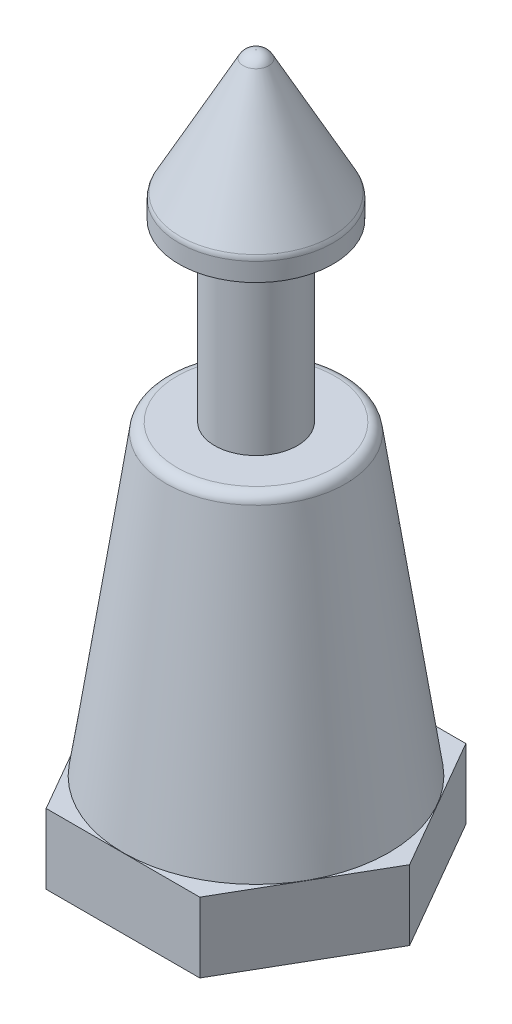
from build123d import *

# Parameters (mm, degrees)
BOSS_EXTRUDE1_DEPTH = 2.54
FILLET1_R           = 0.381
FILLET2_R           = 0.508
SKETCH4_R           = 1.524
CUT_EXTRUDE1_DEPTH  = 11.176
CHAMFER1_SIZE       = 0.762


with BuildPart() as part:
    # Sketch1 → Revolve1 (revolve)
    with BuildSketch(Plane.XY, mode=Mode.PRIVATE) as revolve1_sk:
        Polygon((4.826, 2.4892), (4.826, 0), (0, 0), (0, 25.3492), (0.3175, 25.3492), (2.794, 20.7772), (2.794, 20.0152), (1.4986, 20.0152), (1.4986, 13.6652), (3.2004, 13.6652), align=None)
    revolve(revolve1_sk.sketch.rotate(Axis((0, 0, 0), (0, 1, 0)), 90), axis=Axis((0, 0, 0), (0, 1, 0)))  # turned: the seam where the file's is

    # Sketch2 → Boss-Extrude1 (add)
    with BuildSketch(Plane.XZ):
        Polygon((5.572584798, 0), (2.786292399, 4.826), (-2.786292399, 4.826), (-5.572584798, 0), (-2.786292399, -4.826), (2.786292399, -4.826), align=None)
    extrude(amount=-BOSS_EXTRUDE1_DEPTH)

    # Fillet1
    fillet1_edges = [part.edges().sort_by_distance(p)[0] for p in [
        (0, 13.6652, 3.2004),
        (0, 20.7772, 2.794),
    ]]
    fillet(fillet1_edges, radius=FILLET1_R)

    # Fillet2
    fillet2_edges = [part.edges().sort_by_distance(p)[0] for p in [
        (0, 25.3492, 0.3175),
    ]]
    fillet(fillet2_edges, radius=FILLET2_R)

    # Sketch4 → Cut-Extrude1 (cut)
    with BuildSketch(Plane.XZ):
        with Locations(Location((0, 0, 0), (0, 0, 270))):  # turned: the seam where the file's is
            Circle(SKETCH4_R)
    extrude(amount=-CUT_EXTRUDE1_DEPTH, mode=Mode.SUBTRACT)

    # Chamfer1
    chamfer1_edges = [part.edges().sort_by_distance(p)[0] for p in [
        (0, 0, 1.524),
    ]]
    chamfer(chamfer1_edges, length=CHAMFER1_SIZE)


solid = part.part
